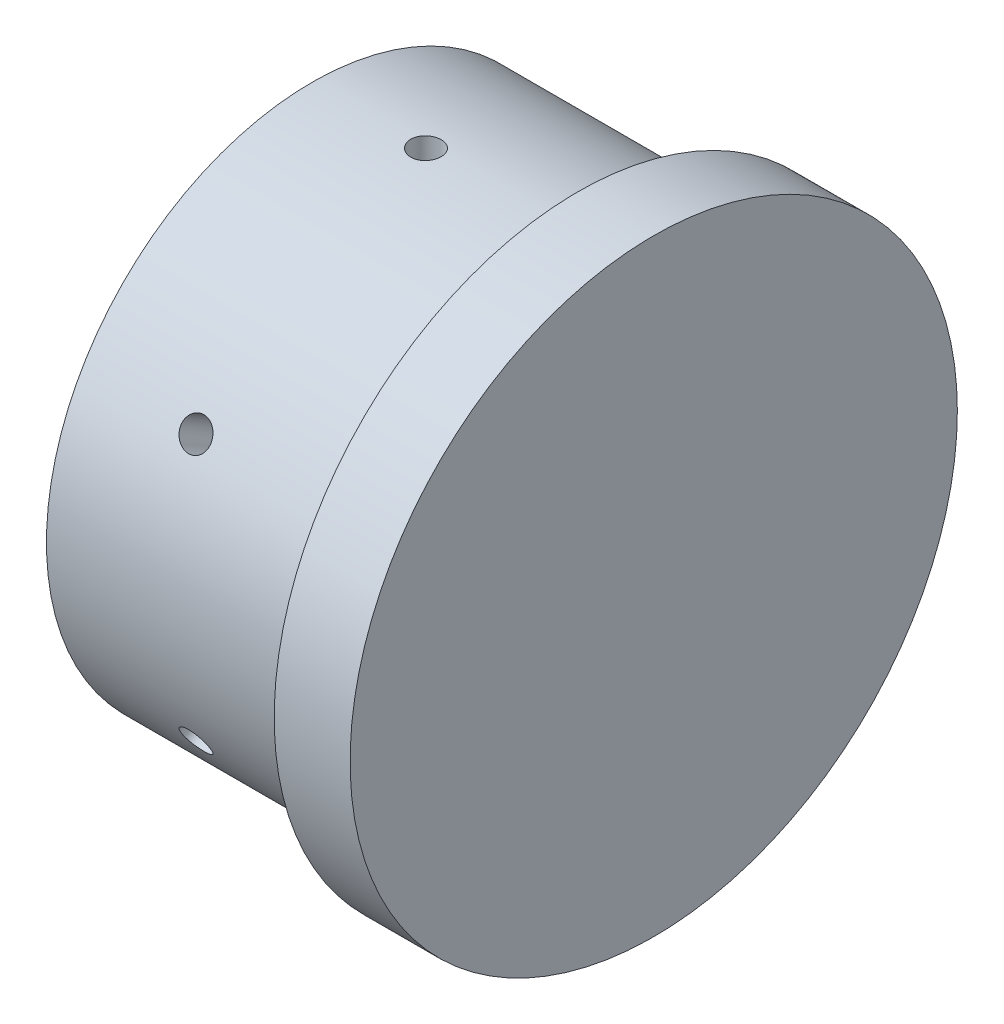
from build123d import *

# Parameters (mm, degrees)
SKETCH1_R           = 35
BOSS_EXTRUDE1_DEPTH = 35
SKETCH2_R           = 40
BOSS_EXTRUDE2_DEPTH = 10
SKETCH3_R           = 2
CUT_EXTRUDE1_DEPTH  = 10
CIRPATTERN1_COUNT   = 6


with BuildPart() as part:
    # Sketch1 → Boss-Extrude1 (new body)
    with BuildSketch(Plane(origin=(0, 0, 0), x_dir=(0, 0, -1), z_dir=(1, 0, 0))):
        Circle(SKETCH1_R)
    extrude(amount=BOSS_EXTRUDE1_DEPTH)

    # Sketch2 → Boss-Extrude2 (add)
    with BuildSketch(Plane(origin=(35, 0, 0), x_dir=(0, 0, -1), z_dir=(1, 0, 0))):
        Circle(SKETCH2_R)
    extrude(amount=BOSS_EXTRUDE2_DEPTH)

    # Sketch3 → Cut-Extrude1 (cut)
    with BuildSketch(Plane(origin=(0, 35, 0), x_dir=(1, 0, 0), z_dir=(0, 1, 0))):
        with Locations((15, 0)):
            Circle(SKETCH3_R)
    cut_extrude1 = extrude(amount=-CUT_EXTRUDE1_DEPTH, mode=Mode.SUBTRACT)

    # CirPattern1: Cut-Extrude1 ×6 about axis
    cirpattern1_axis = Axis((0, 0, 0), (1, 0, 0))
    for i in range(1, CIRPATTERN1_COUNT):
        add(cut_extrude1.rotate(cirpattern1_axis, i * 360 / CIRPATTERN1_COUNT), mode=Mode.SUBTRACT)


solid = part.part
